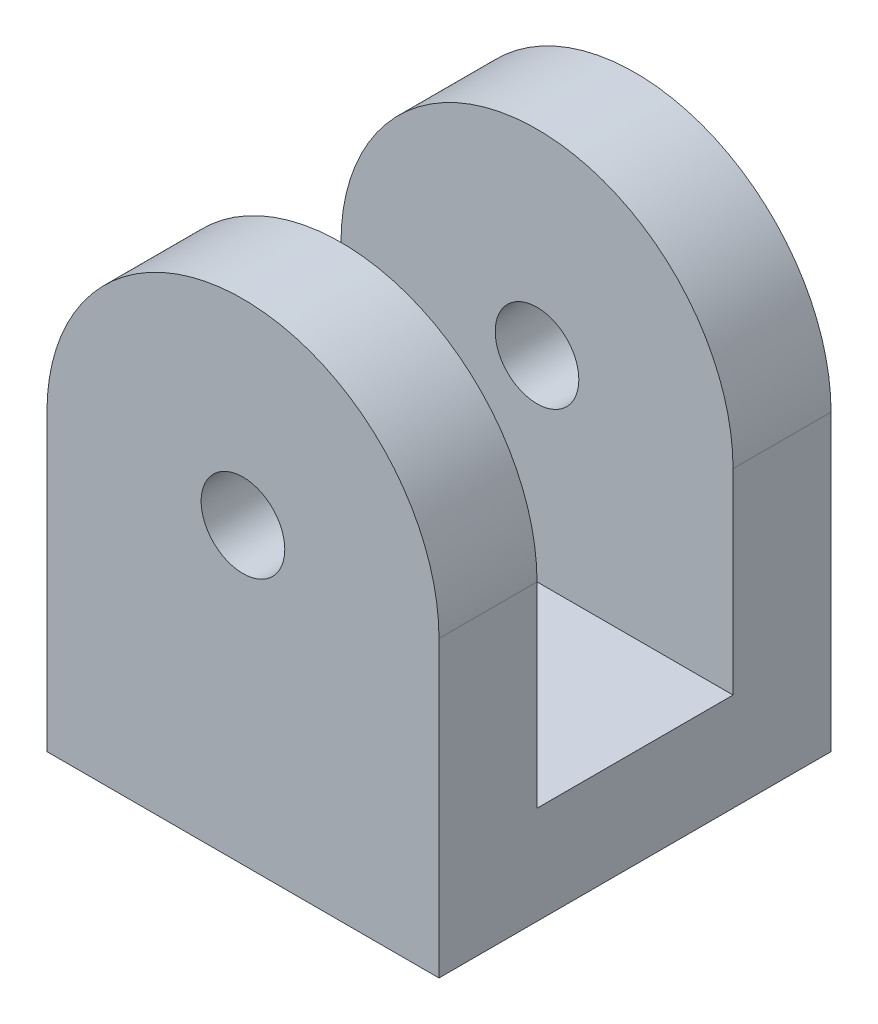
from build123d import *

# Parameters (mm, degrees)
SKETCH1_W               = 15
SKETCH1_H               = 3.75
BOSS_EXTRUDE1_DEPTH     = 7.5
SKETCH2_W               = 15
SKETCH2_H               = 3.75
BOSS_EXTRUDE2_DEPTH     = 15
SKETCH3_R               = 1.6
CUT_EXTRUDE1_DEPTH      = 20.931523399
CUT_EXTRUDE1_DEPTH_BACK = 3.75


with BuildPart() as part:
    # Sketch1 → Boss-Extrude1 (new body)
    with BuildSketch(Plane.XY):
        Rectangle(SKETCH1_W, SKETCH1_H)
    extrude(amount=BOSS_EXTRUDE1_DEPTH)

    # Sketch2 → Boss-Extrude2 (add)
    with BuildSketch(Plane(origin=(0, 1.875, 0), x_dir=(1, 0, 0), z_dir=(0, 1, 0))):
        with Locations((0, -5.625)):
            Rectangle(SKETCH2_W, SKETCH2_H)
    extrude(amount=BOSS_EXTRUDE2_DEPTH)

    # Sketch3 → Cut-Extrude1 (cut, two sides)
    with BuildSketch(Plane.XY.offset(7.5)) as cut_extrude1_sk:
        with Locations((0, 9.375)):
            Circle(SKETCH3_R)
        with BuildLine():
            ThreePointArc((-3e-08, 16.875), (5.303300848, 14.67830087), (7.5, 9.375))
            Line((7.5, 9.375), (7.5, 16.875))
            Line((7.5, 16.875), (-3e-08, 16.875))
        make_face()
        with BuildLine():
            ThreePointArc((-7.5, 9.375), (-5.30330087, 14.678300848), (-3e-08, 16.875))
            Line((-3e-08, 16.875), (-7.5, 16.875))
            Line((-7.5, 16.875), (-7.5, 9.375))
        make_face()
    extrude(amount=CUT_EXTRUDE1_DEPTH, mode=Mode.SUBTRACT)
    extrude(cut_extrude1_sk.sketch, amount=-CUT_EXTRUDE1_DEPTH_BACK, mode=Mode.SUBTRACT)

    # Mirror1: part across plane


with BuildPart() as part_1:
    add(part.part)
    add(part.part.mirror(Plane(origin=(0, 0, 0), x_dir=(1, 0, 0), z_dir=(0, 0, -1))))


solid = part_1.part
